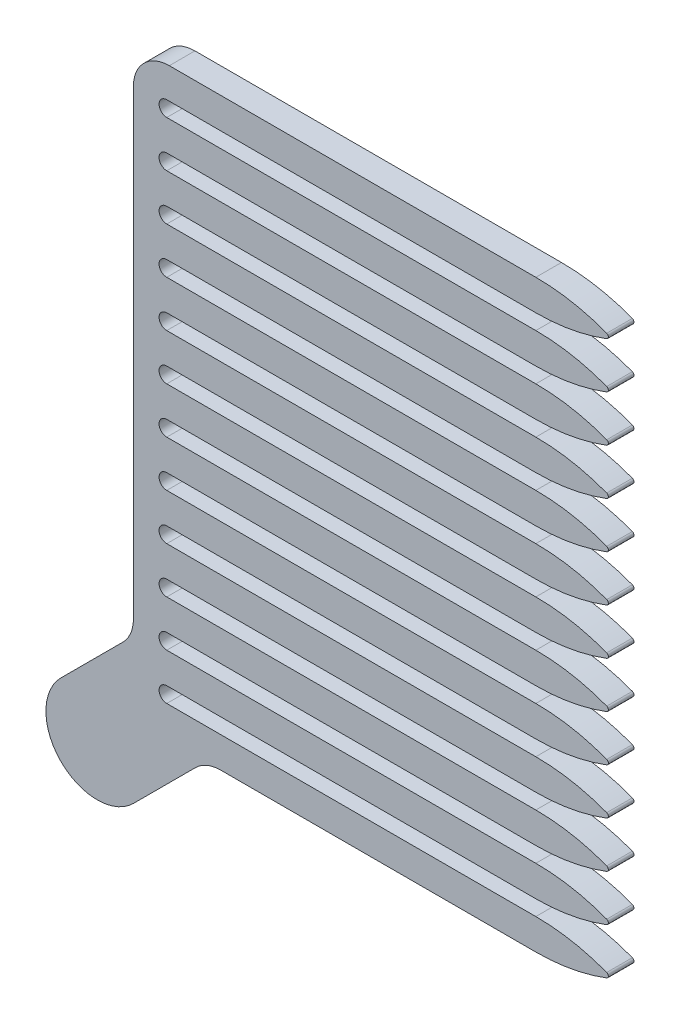
from build123d import *

# Parameters (mm, degrees)
AUFSATZ_LINEAR_AUSTRAGEN1_DEPTH = 5
SKIZZE2_R                       = 1.5
SCHNITT_LINEAR_AUSTRAGEN1_DEPTH = 6
VERRUNDUNG2_R                   = 0.5
LINEARES_MUSTER1_COUNT          = 13
LINEARES_MUSTER1_PITCH          = 9
SKIZZE3_W                       = 7.361940712
SKIZZE3_H                       = 3
SCHNITT_LINEAR_AUSTRAGEN2_DEPTH = 6.0000001
AUFSATZ_LINEAR_AUSTRAGEN2_DEPTH = 5
VERRUNDUNG1_R                   = 7


with BuildPart() as part:
    # Skizze1 → Aufsatz-Linear austragen1 (new body)
    with BuildSketch(Plane.XY):
        with BuildLine():
            Line((0, 3), (-78.5, 3))
            Line((-78.5, 3), (-78.5, -1.933446409))
            Line((-78.5, -1.933446409), (-78.5, -6))
            Line((-78.5, -6), (-72, -6))
            Line((-72, -6), (-72, -3))
            Line((-72, -3), (0, -3))
            ThreePointArc((0, -3), (7.64852927, -2.242646352), (15, 0))
            ThreePointArc((15, 0), (7.64852927, 2.242646352), (0, 3))
        make_face()
    extrude(amount=AUFSATZ_LINEAR_AUSTRAGEN1_DEPTH)

    # Skizze2 → Schnitt-Linear austragen1 (cut, through all)
    with BuildSketch(Plane.XY.offset(5)):
        with Locations((-72, -4.5)):
            Circle(SKIZZE2_R)
    extrude(amount=-SCHNITT_LINEAR_AUSTRAGEN1_DEPTH, mode=Mode.SUBTRACT)

    # Verrundung2
    verrundung2_edges = [part.edges().sort_by_distance(p)[0] for p in [
        (15, 0, 2.5),
    ]]
    fillet(verrundung2_edges, radius=VERRUNDUNG2_R)


with BuildPart() as lineares_muster1_1:
    # Lineares Muster1: pattern copy
    add(part.part.moved(Location(Vector(0, -1, 0) * (1 * LINEARES_MUSTER1_PITCH))))


with BuildPart() as lineares_muster1_2:
    # Lineares Muster1: pattern copy
    add(part.part.moved(Location(Vector(0, -1, 0) * (2 * LINEARES_MUSTER1_PITCH))))


with BuildPart() as lineares_muster1_3:
    # Lineares Muster1: pattern copy
    add(part.part.moved(Location(Vector(0, -1, 0) * (3 * LINEARES_MUSTER1_PITCH))))


with BuildPart() as lineares_muster1_4:
    # Lineares Muster1: pattern copy
    add(part.part.moved(Location(Vector(0, -1, 0) * (4 * LINEARES_MUSTER1_PITCH))))


with BuildPart() as lineares_muster1_5:
    # Lineares Muster1: pattern copy
    add(part.part.moved(Location(Vector(0, -1, 0) * (5 * LINEARES_MUSTER1_PITCH))))


with BuildPart() as lineares_muster1_6:
    # Lineares Muster1: pattern copy
    add(part.part.moved(Location(Vector(0, -1, 0) * (6 * LINEARES_MUSTER1_PITCH))))


with BuildPart() as lineares_muster1_7:
    # Lineares Muster1: pattern copy
    add(part.part.moved(Location(Vector(0, -1, 0) * (7 * LINEARES_MUSTER1_PITCH))))


with BuildPart() as lineares_muster1_8:
    # Lineares Muster1: pattern copy
    add(part.part.moved(Location(Vector(0, -1, 0) * (8 * LINEARES_MUSTER1_PITCH))))


with BuildPart() as lineares_muster1_9:
    # Lineares Muster1: pattern copy
    add(part.part.moved(Location(Vector(0, -1, 0) * (9 * LINEARES_MUSTER1_PITCH))))


with BuildPart() as lineares_muster1_10:
    # Lineares Muster1: pattern copy
    add(part.part.moved(Location(Vector(0, -1, 0) * (10 * LINEARES_MUSTER1_PITCH))))


with BuildPart() as lineares_muster1_11:
    # Lineares Muster1: pattern copy
    add(part.part.moved(Location(Vector(0, -1, 0) * (11 * LINEARES_MUSTER1_PITCH))))


with BuildPart() as lineares_muster1_12:
    # Lineares Muster1: pattern copy
    add(part.part.moved(Location(Vector(0, -1, 0) * (12 * LINEARES_MUSTER1_PITCH))))


with BuildPart() as part_1:
    add(part.part)

    # Kombinieren1: union Lineares Muster1_1, Lineares Muster1_2, Lineares Muster1_3, Lineares Muster1_4, Lineares Muster1_5, Lineares Muster1_6, Lineares Muster1_7, Lineares Muster1_8, Lineares Muster1_9, Lineares Muster1_10, Lineares Muster1_11, Lineares Muster1_12
    add(lineares_muster1_1.part)
    add(lineares_muster1_2.part)
    add(lineares_muster1_3.part)
    add(lineares_muster1_4.part)
    add(lineares_muster1_5.part)
    add(lineares_muster1_6.part)
    add(lineares_muster1_7.part)
    add(lineares_muster1_8.part)
    add(lineares_muster1_9.part)
    add(lineares_muster1_10.part)
    add(lineares_muster1_11.part)
    add(lineares_muster1_12.part)

    # Skizze3 → Schnitt-Linear austragen2 (cut, through all)
    with BuildSketch(Plane.XY.offset(5)):
        with Locations((-74.819029644, -112.5)):
            Rectangle(SKIZZE3_W, SKIZZE3_H)
    extrude(amount=-SCHNITT_LINEAR_AUSTRAGEN2_DEPTH, mode=Mode.SUBTRACT)

    # Skizze4 → Aufsatz-Linear austragen2 (add)
    with BuildSketch(Plane.XY.offset(5)):
        with BuildLine():
            Line((-64.357864376, -111), (-78.5, -111))
            Line((-78.5, -111), (-78.5, -96.857864376))
            Line((-78.5, -96.857864376), (-92.642135624, -111))
            ThreePointArc((-92.642135624, -111), (-92.642135624, -125.142135624), (-78.5, -125.142135624))
            Line((-78.5, -125.142135624), (-64.357864376, -111))
        make_face()
    extrude(amount=-AUFSATZ_LINEAR_AUSTRAGEN2_DEPTH)

    # Verrundung1
    verrundung1_edges = [part_1.edges().sort_by_distance(p)[0] for p in [
        (-78.5, 3, 2.5),
        (-64.357864376, -111, 2.5),
        (-78.5, -96.857864376, 2.5),
    ]]
    fillet(verrundung1_edges, radius=VERRUNDUNG1_R)


solid = part_1.part
